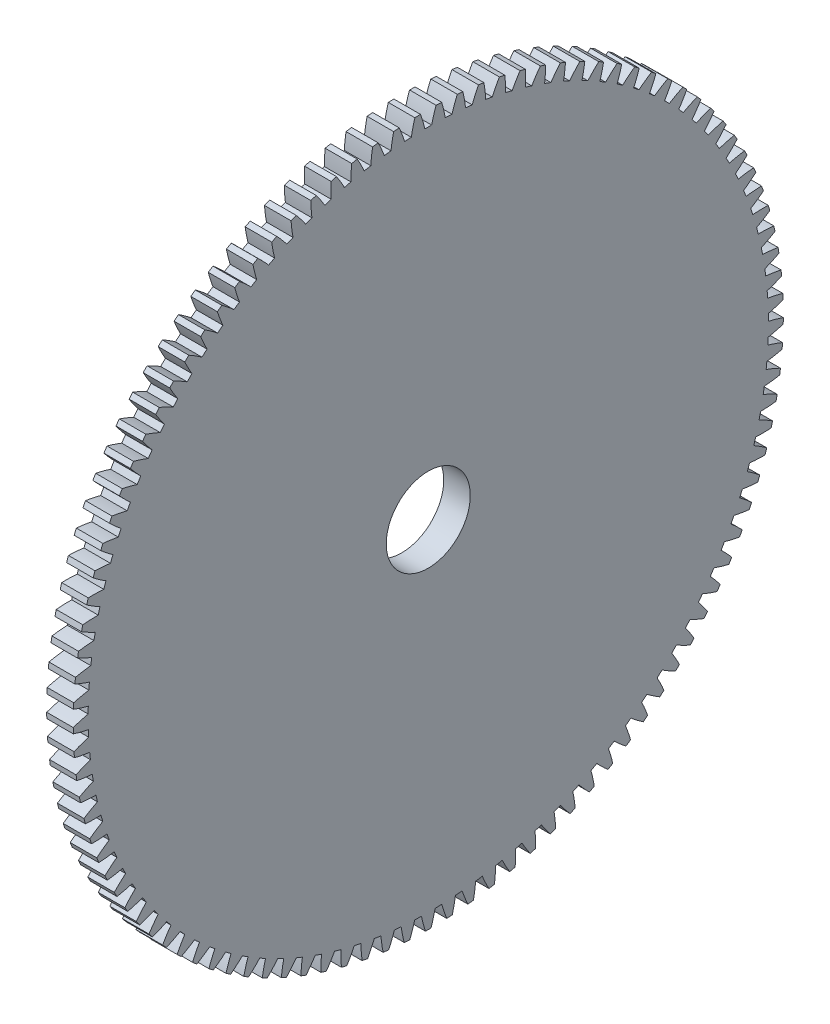
from build123d import *

# Parameters (mm, degrees)
BASPROSKE_W     = 12
BASPROSKE_H     = 160.5
TOOTHCUT_DEPTH  = 228.298262202
TEETHCUTS_COUNT = 105
TEETHCUTS_ANGLE = 356.571428571
BORSKE_R        = 19
BORE_DEPTH      = 50.0000508


with BuildPart() as part:
    # BasProSke → Base-Revolve (revolve)
    with BuildSketch(Plane(origin=(0, 0, 0), x_dir=(1, 0, 0), z_dir=(0, 1, 0)), mode=Mode.PRIVATE) as base_revolve_sk:
        with Locations((6, 80.25)):
            Rectangle(BASPROSKE_W, BASPROSKE_H)
    revolve(base_revolve_sk.sketch.rotate(Axis((-10, 0, 0), (1, 0, 0)), 180), axis=Axis((-10, 0, 0), (1, 0, 0)))

    # TooCutSke → ToothCut (cut, through all)
    with BuildSketch(Plane(origin=(0, 0, 0), x_dir=(0, 0, -1), z_dir=(1, 0, 0))):
        with BuildLine():
            ThreePointArc((1.519002972, 153.741496126), (0, 153.749), (-1.519002972, 153.741496126))
            ThreePointArc((-1.519002972, 153.741496126), (-2.440717313, 157.142230179), (-3.551110118, 160.486116727))
            ThreePointArc((-3.551110118, 160.486116727), (0, 160.5254), (3.551110118, 160.486116727))
            ThreePointArc((3.551110118, 160.486116727), (2.440717313, 157.142230179), (1.519002972, 153.741496126))
        make_face()
    toothcut = extrude(amount=TOOTHCUT_DEPTH, mode=Mode.SUBTRACT)

    # TeethCuts: ToothCut ×105 about axis
    teethcuts_axis = Axis((-10, 0, 0), (1, 0, 0))
    for i in range(1, TEETHCUTS_COUNT):
        add(toothcut.rotate(teethcuts_axis, i * TEETHCUTS_ANGLE / (TEETHCUTS_COUNT - 1)), mode=Mode.SUBTRACT)

    # BorSke → Bore (cut, symmetric)
    with BuildSketch(Plane(origin=(0, 0, 0), x_dir=(0, 0, -1), z_dir=(1, 0, 0))):
        with Locations(Location((0, 0, 0), (0, 0, 180))):
            Circle(BORSKE_R)
    extrude(amount=BORE_DEPTH, both=True, mode=Mode.SUBTRACT)


solid = part.part
